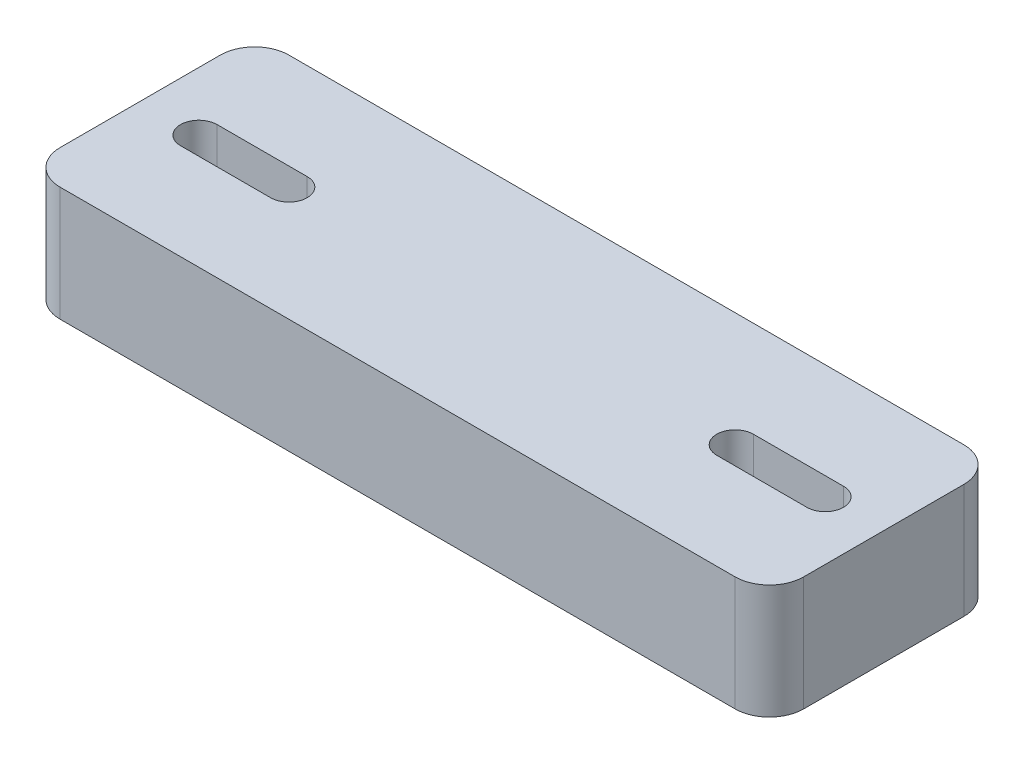
from build123d import *

# Parameters (mm, degrees)
SKETCH_1_W          = 65
SKETCH_1_H          = 20
EXTRUDE_1_DEPTH     = 10
CUT_EXTRUDE_1_DEPTH = 10
FILLET_1_R          = 3


with BuildPart() as part:
    # 草图1 → 凸台-拉伸1 (new body)
    with BuildSketch(Plane(origin=(0, 0, 0), x_dir=(1, 0, 0), z_dir=(0, 1, 0))):
        Rectangle(SKETCH_1_W, SKETCH_1_H)
    extrude(amount=EXTRUDE_1_DEPTH)

    # 草图2 → 切除-拉伸1 (cut)
    with BuildSketch(Plane(origin=(0, 10, 0), x_dir=(1, 0, 0), z_dir=(0, 1, 0))):
        with BuildLine():
            Line((-27.375, 1.6), (-19.5, 1.6))
            ThreePointArc((-19.5, 1.6), (-17.9, 0), (-19.5, -1.6))
            Line((-19.5, -1.6), (-27.375, -1.6))
            ThreePointArc((-27.375, -1.6), (-28.975, 0), (-27.375, 1.6))
        make_face()
        with BuildLine():
            Line((27.375, 1.6), (19.5, 1.6))
            ThreePointArc((19.5, 1.6), (17.9, 0), (19.5, -1.6))
            Line((19.5, -1.6), (27.375, -1.6))
            ThreePointArc((27.375, -1.6), (28.975, 0), (27.375, 1.6))
        make_face()
    extrude(amount=-CUT_EXTRUDE_1_DEPTH, mode=Mode.SUBTRACT)

    # 圆角1
    fillet_1_edges = [part.edges().sort_by_distance(p)[0] for p in [
        (32.5, 5, 10),
        (-32.5, 5, 10),
        (-32.5, 5, -10),
        (32.5, 5, -10),
    ]]
    fillet(fillet_1_edges, radius=FILLET_1_R)


solid = part.part
